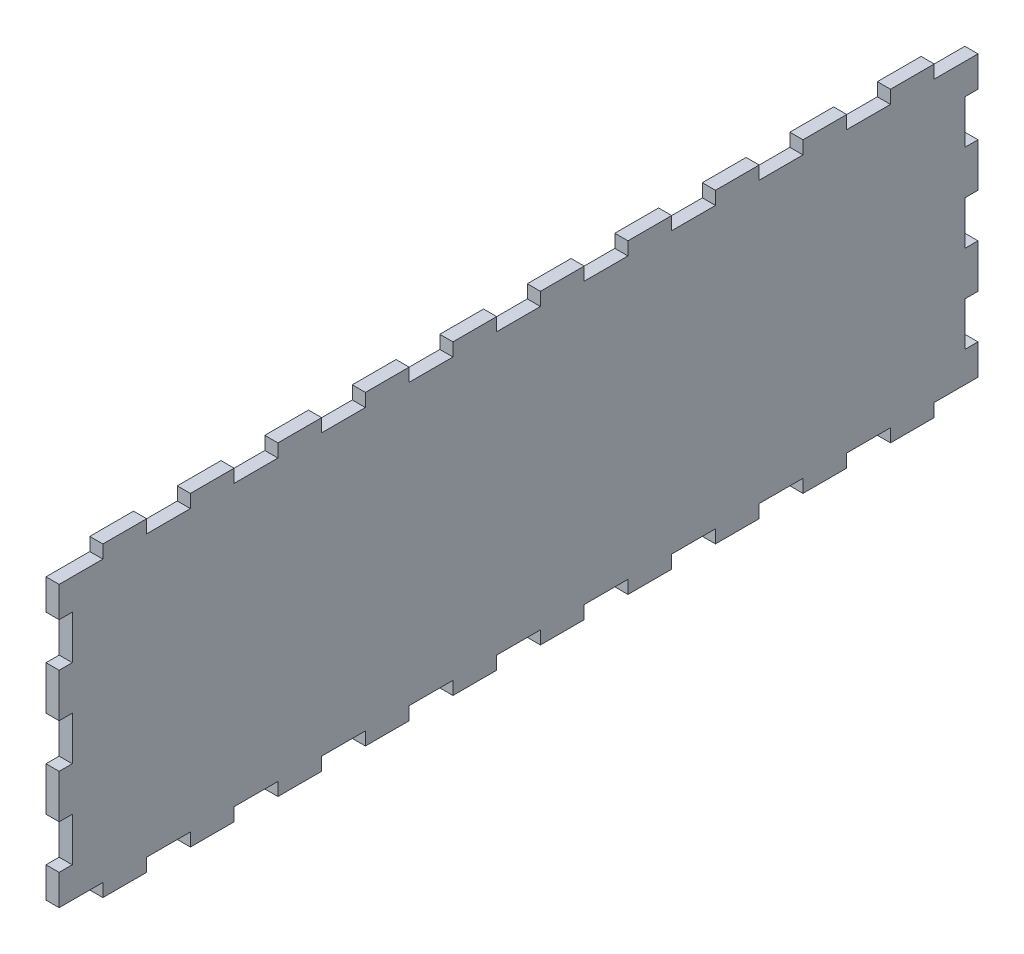
from build123d import *

# Parameters (mm, degrees)
SKETCH1_W                = 210
SKETCH1_H                = 70
BOSS_EXTRUDE1_DEPTH      = 3
SKETCH2_W                = 10
SKETCH2_H                = 3
CUT_EXTRUDE1_DEPTH       = 3
LPATTERN1_COUNT          = 11
LPATTERN1_PITCH          = 20
MIRROR1_COPY_1_SKETCH_W  = 10
MIRROR1_COPY_1_SKETCH_H  = 3
MIRROR1_COPY_1_DEPTH     = 3
MIRROR1_COPY_2_SKETCH_W  = 10
MIRROR1_COPY_2_SKETCH_H  = 3
MIRROR1_COPY_2_DEPTH     = 3
MIRROR1_COPY_3_SKETCH_W  = 10
MIRROR1_COPY_3_SKETCH_H  = 3
MIRROR1_COPY_3_DEPTH     = 3
MIRROR1_COPY_4_SKETCH_W  = 10
MIRROR1_COPY_4_SKETCH_H  = 3
MIRROR1_COPY_4_DEPTH     = 3
MIRROR1_COPY_5_SKETCH_W  = 10
MIRROR1_COPY_5_SKETCH_H  = 3
MIRROR1_COPY_5_DEPTH     = 3
MIRROR1_COPY_6_SKETCH_W  = 10
MIRROR1_COPY_6_SKETCH_H  = 3
MIRROR1_COPY_6_DEPTH     = 3
MIRROR1_COPY_7_SKETCH_W  = 10
MIRROR1_COPY_7_SKETCH_H  = 3
MIRROR1_COPY_7_DEPTH     = 3
MIRROR1_COPY_8_SKETCH_W  = 10
MIRROR1_COPY_8_SKETCH_H  = 3
MIRROR1_COPY_8_DEPTH     = 3
MIRROR1_COPY_9_SKETCH_W  = 10
MIRROR1_COPY_9_SKETCH_H  = 3
MIRROR1_COPY_9_DEPTH     = 3
MIRROR1_COPY_10_SKETCH_W = 10
MIRROR1_COPY_10_SKETCH_H = 3
MIRROR1_COPY_10_DEPTH    = 3
SKETCH3_W                = 3
SKETCH3_H                = 10
CUT_EXTRUDE2_DEPTH       = 3
LPATTERN2_COUNT          = 3
LPATTERN2_PITCH          = 20
MIRROR2_COPY_1_SKETCH_W  = 3
MIRROR2_COPY_1_SKETCH_H  = 10
MIRROR2_COPY_1_DEPTH     = 3
MIRROR2_COPY_2_SKETCH_W  = 3
MIRROR2_COPY_2_SKETCH_H  = 10
MIRROR2_COPY_2_DEPTH     = 3


with BuildPart() as part:
    # Sketch1 → Boss-Extrude1 (new body)
    with BuildSketch(Plane(origin=(0, 0, 0), x_dir=(0, 0, -1), z_dir=(1, 0, 0))):
        Rectangle(SKETCH1_W, SKETCH1_H)
    extrude(amount=BOSS_EXTRUDE1_DEPTH)

    # Sketch2 → Cut-Extrude1 (cut)
    with BuildSketch(Plane(origin=(3, 0, 0), x_dir=(0, 0, -1), z_dir=(1, 0, 0))):
        with Locations((-100, 33.5)):
            Rectangle(SKETCH2_W, SKETCH2_H)
    cut_extrude1 = extrude(amount=-CUT_EXTRUDE1_DEPTH, mode=Mode.SUBTRACT)

    # LPattern1: Cut-Extrude1 ×11
    with Locations(*[(0, 0, -i * LPATTERN1_PITCH) for i in range(1, LPATTERN1_COUNT)]):
        add(cut_extrude1, mode=Mode.SUBTRACT)

    # Mirror1: Cut-Extrude1 across plane
    add(cut_extrude1.mirror(Plane.ZX), mode=Mode.SUBTRACT)

    # Mirror1 copy 1 sketch → Mirror1 copy 1 (cut)
    with BuildSketch(Plane(origin=(3, 0, -20), x_dir=(0, 0, -1), z_dir=(1, 0, 0))):
        with Locations((-100, -33.5)):
            Rectangle(MIRROR1_COPY_1_SKETCH_W, MIRROR1_COPY_1_SKETCH_H)
    extrude(amount=-MIRROR1_COPY_1_DEPTH, mode=Mode.SUBTRACT)

    # Mirror1 copy 2 sketch → Mirror1 copy 2 (cut)
    with BuildSketch(Plane(origin=(3, 0, -40), x_dir=(0, 0, -1), z_dir=(1, 0, 0))):
        with Locations((-100, -33.5)):
            Rectangle(MIRROR1_COPY_2_SKETCH_W, MIRROR1_COPY_2_SKETCH_H)
    extrude(amount=-MIRROR1_COPY_2_DEPTH, mode=Mode.SUBTRACT)

    # Mirror1 copy 3 sketch → Mirror1 copy 3 (cut)
    with BuildSketch(Plane(origin=(3, 0, -60), x_dir=(0, 0, -1), z_dir=(1, 0, 0))):
        with Locations((-100, -33.5)):
            Rectangle(MIRROR1_COPY_3_SKETCH_W, MIRROR1_COPY_3_SKETCH_H)
    extrude(amount=-MIRROR1_COPY_3_DEPTH, mode=Mode.SUBTRACT)

    # Mirror1 copy 4 sketch → Mirror1 copy 4 (cut)
    with BuildSketch(Plane(origin=(3, 0, -80), x_dir=(0, 0, -1), z_dir=(1, 0, 0))):
        with Locations((-100, -33.5)):
            Rectangle(MIRROR1_COPY_4_SKETCH_W, MIRROR1_COPY_4_SKETCH_H)
    extrude(amount=-MIRROR1_COPY_4_DEPTH, mode=Mode.SUBTRACT)

    # Mirror1 copy 5 sketch → Mirror1 copy 5 (cut)
    with BuildSketch(Plane(origin=(3, 0, -100), x_dir=(0, 0, -1), z_dir=(1, 0, 0))):
        with Locations((-100, -33.5)):
            Rectangle(MIRROR1_COPY_5_SKETCH_W, MIRROR1_COPY_5_SKETCH_H)
    extrude(amount=-MIRROR1_COPY_5_DEPTH, mode=Mode.SUBTRACT)

    # Mirror1 copy 6 sketch → Mirror1 copy 6 (cut)
    with BuildSketch(Plane(origin=(3, 0, -120), x_dir=(0, 0, -1), z_dir=(1, 0, 0))):
        with Locations((-100, -33.5)):
            Rectangle(MIRROR1_COPY_6_SKETCH_W, MIRROR1_COPY_6_SKETCH_H)
    extrude(amount=-MIRROR1_COPY_6_DEPTH, mode=Mode.SUBTRACT)

    # Mirror1 copy 7 sketch → Mirror1 copy 7 (cut)
    with BuildSketch(Plane(origin=(3, 0, -140), x_dir=(0, 0, -1), z_dir=(1, 0, 0))):
        with Locations((-100, -33.5)):
            Rectangle(MIRROR1_COPY_7_SKETCH_W, MIRROR1_COPY_7_SKETCH_H)
    extrude(amount=-MIRROR1_COPY_7_DEPTH, mode=Mode.SUBTRACT)

    # Mirror1 copy 8 sketch → Mirror1 copy 8 (cut)
    with BuildSketch(Plane(origin=(3, 0, -160), x_dir=(0, 0, -1), z_dir=(1, 0, 0))):
        with Locations((-100, -33.5)):
            Rectangle(MIRROR1_COPY_8_SKETCH_W, MIRROR1_COPY_8_SKETCH_H)
    extrude(amount=-MIRROR1_COPY_8_DEPTH, mode=Mode.SUBTRACT)

    # Mirror1 copy 9 sketch → Mirror1 copy 9 (cut)
    with BuildSketch(Plane(origin=(3, 0, -180), x_dir=(0, 0, -1), z_dir=(1, 0, 0))):
        with Locations((-100, -33.5)):
            Rectangle(MIRROR1_COPY_9_SKETCH_W, MIRROR1_COPY_9_SKETCH_H)
    extrude(amount=-MIRROR1_COPY_9_DEPTH, mode=Mode.SUBTRACT)

    # Mirror1 copy 10 sketch → Mirror1 copy 10 (cut)
    with BuildSketch(Plane(origin=(3, 0, -200), x_dir=(0, 0, -1), z_dir=(1, 0, 0))):
        with Locations((-100, -33.5)):
            Rectangle(MIRROR1_COPY_10_SKETCH_W, MIRROR1_COPY_10_SKETCH_H)
    extrude(amount=-MIRROR1_COPY_10_DEPTH, mode=Mode.SUBTRACT)

    # Sketch3 → Cut-Extrude2 (cut)
    with BuildSketch(Plane(origin=(3, 0, 0), x_dir=(0, 0, -1), z_dir=(1, 0, 0))):
        with Locations((-103.5, 20)):
            Rectangle(SKETCH3_W, SKETCH3_H)
    cut_extrude2 = extrude(amount=-CUT_EXTRUDE2_DEPTH, mode=Mode.SUBTRACT)

    # LPattern2: Cut-Extrude2 ×3
    with Locations(*[(0, -i * LPATTERN2_PITCH, 0) for i in range(1, LPATTERN2_COUNT)]):
        add(cut_extrude2, mode=Mode.SUBTRACT)

    # Mirror2: Cut-Extrude2 across plane
    add(cut_extrude2.mirror(Plane.XY), mode=Mode.SUBTRACT)

    # Mirror2 copy 1 sketch → Mirror2 copy 1 (cut)
    with BuildSketch(Plane(origin=(3, -20, 0), x_dir=(0, 0, 1), z_dir=(1, 0, 0))):
        with Locations((-103.5, -20)):
            Rectangle(MIRROR2_COPY_1_SKETCH_W, MIRROR2_COPY_1_SKETCH_H)
    extrude(amount=-MIRROR2_COPY_1_DEPTH, mode=Mode.SUBTRACT)

    # Mirror2 copy 2 sketch → Mirror2 copy 2 (cut)
    with BuildSketch(Plane(origin=(3, -40, 0), x_dir=(0, 0, 1), z_dir=(1, 0, 0))):
        with Locations((-103.5, -20)):
            Rectangle(MIRROR2_COPY_2_SKETCH_W, MIRROR2_COPY_2_SKETCH_H)
    extrude(amount=-MIRROR2_COPY_2_DEPTH, mode=Mode.SUBTRACT)


solid = part.part
